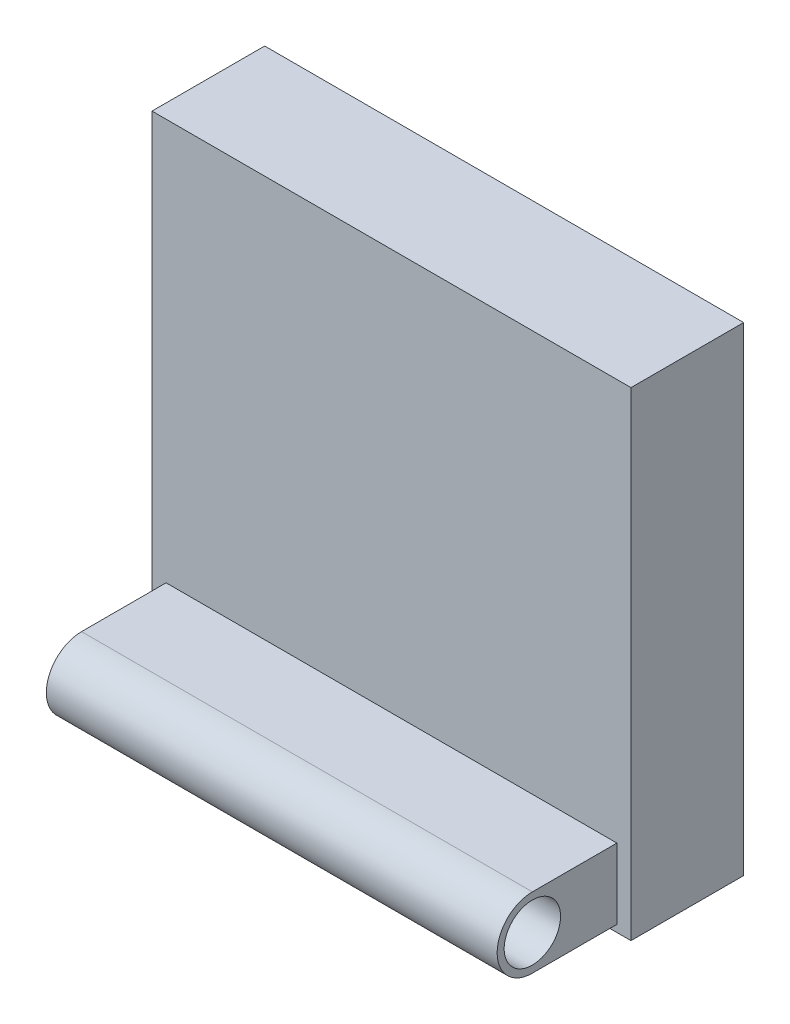
from build123d import *

# Parameters (mm, degrees)
ESQUISSE1_W        = 34
ESQUISSE1_H        = 34
BOSS_EXTRU_1_DEPTH = 8
BOSS_EXTRU_2_START = 1
ESQUISSE2_R        = 2
BOSS_EXTRU_2_DEPTH = 32


with BuildPart() as part:
    # Esquisse1 → Boss.-Extru.1 (new body)
    with BuildSketch(Plane.XY):
        with Locations((17, 17)):
            Rectangle(ESQUISSE1_W, ESQUISSE1_H)
    extrude(amount=BOSS_EXTRU_1_DEPTH)

    # Esquisse2 → Boss.-Extru.2 (add)
    with BuildSketch(Plane(origin=(0, 0, 0), x_dir=(0, 0, -1), z_dir=(1, 0, 0)).offset(BOSS_EXTRU_2_START)):
        with BuildLine():
            Line((-8, 5.5), (-14, 5.5))
            ThreePointArc((-14, 5.5), (-16.5, 3), (-14, 0.5))
            Line((-14, 0.5), (-8, 0.5))
            Line((-8, 0.5), (-8, 5.5))
        make_face()
        with Locations((-14, 3)):
            Circle(ESQUISSE2_R, mode=Mode.SUBTRACT)
    extrude(amount=BOSS_EXTRU_2_DEPTH)


solid = part.part
